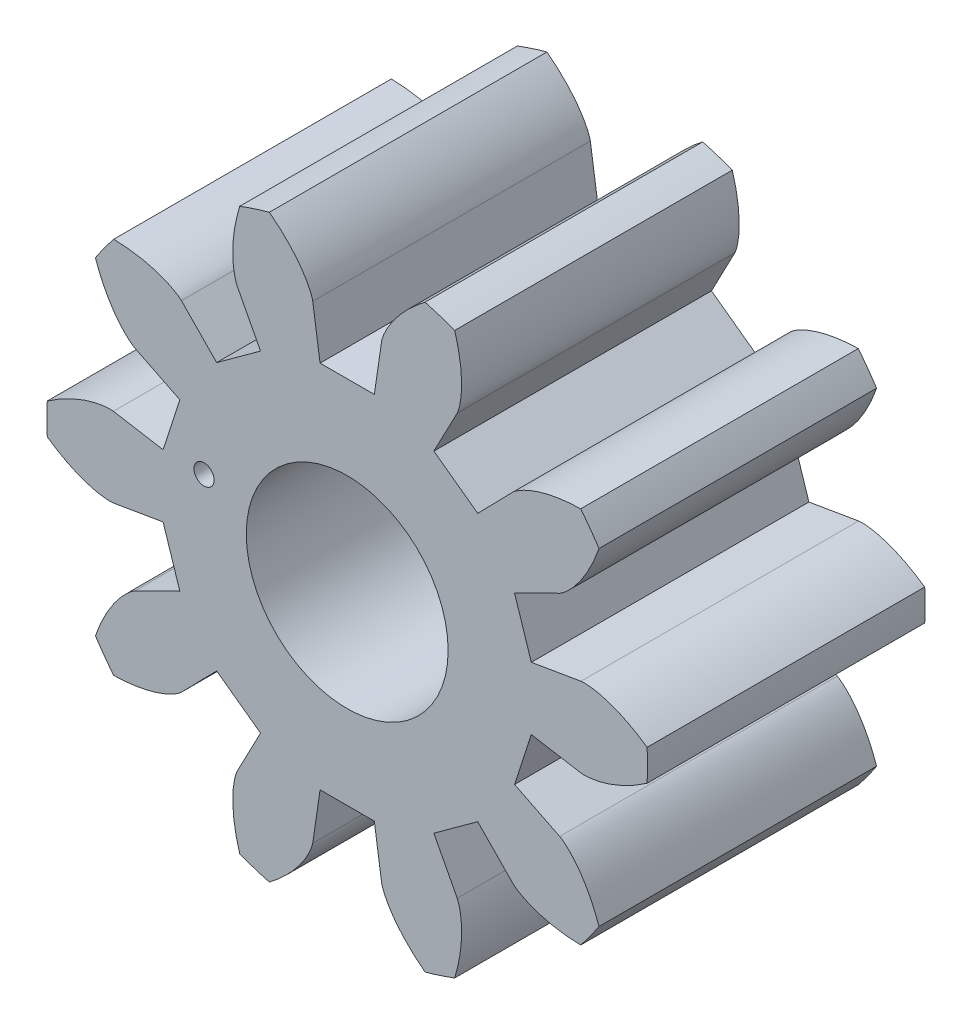
from build123d import *

# Parameters (mm, degrees)
SKETCH2_R               = 2.975
BOSS_EXTRUDE1_DEPTH     = 2.75
CUT_EXTRUDE2_DEPTH      = 6.0263058
CIRPATTERN1_COUNT       = 10
SKETCH3_R               = 1
CUT_EXTRUDE3_DEPTH      = 5.966777819
CUT_EXTRUDE6_DEPTH      = 5.966777819
CUT_EXTRUDE6_DEPTH_BACK = 5.966777819
SKETCH8_R               = 0.1


with BuildPart() as part:
    # Sketch2 → Boss-Extrude1 (new body)
    with BuildSketch(Plane.XY):
        Circle(SKETCH2_R)
    extrude(amount=BOSS_EXTRUDE1_DEPTH)

    # Sketch1 → Cut-Extrude2 (cut, through all)
    with BuildSketch(Plane.XY):
        with BuildLine():
            Line((2.105061689, 1.042882625), (1.657718296, 0.821261256))
            Line((1.657718296, 0.821261256), (1.823847528, 0.309968054))
            Line((1.823847528, 0.309968054), (2.316021708, 0.393614449))
            add(Edge.make_bspline(
                [(2.316021708, 0.393614449), (2.318929636, 0.394059611), (2.32446792, 0.394624012), (2.333537567, 0.395243685), (2.351499628, 0.395693398), (2.37186071, 0.395143687), (2.394878514, 0.393478775), (2.41960709, 0.390646462), (2.440730041, 0.387578139), (2.461769783, 0.383916799), (2.482692036, 0.379728548), (2.507978463, 0.3740182), (2.53821109, 0.366286196), (2.573383265, 0.35596726), (2.613051112, 0.342756753), (2.653190086, 0.327695817), (2.692432613, 0.311567142), (2.731740766, 0.293783952), (2.76952819, 0.275524287), (2.808369263, 0.255057903), (2.844018113, 0.235400613), (2.883451084, 0.211741965), (2.91513058, 0.192169028), (2.947397089, 0.170604832), (2.963032024, 0.159911869), (2.97099254, 0.154364272)],
                knots=[0, 0, 0, 0, 0, 0.015083688, 0.02853182, 0.046610139, 0.092110525, 0.119476176, 0.146842496, 0.174208854, 0.201574956, 0.228941013, 0.256307345, 0.307035032, 0.361767352, 0.416499661, 0.471231936, 0.525964282, 0.580696615, 0.635428982, 0.690161387, 0.744893688, 0.799626082, 0.854358408, 0.909090915, 0.909090915, 0.909090915, 0.909090915, 0.909090915], degree=4))
            ThreePointArc((2.97099254, 0.154364272), (2.829393136, 0.919325558), (2.494316497, 1.62142228))
            add(Edge.make_bspline(
                [(2.105061689, 1.042882625), (2.107675912, 1.044231719), (2.112488225, 1.047030431), (2.120189957, 1.05186011), (2.134985906, 1.062054119), (2.151135254, 1.074466788), (2.168778438, 1.089343256), (2.187119485, 1.106169737), (2.202404796, 1.121067821), (2.217274223, 1.136396758), (2.231738889, 1.152082916), (2.24883958, 1.171565673), (2.268753531, 1.195591288), (2.2911431, 1.224613169), (2.315470121, 1.258616869), (2.339090638, 1.294394519), (2.361358312, 1.33050907), (2.382706578, 1.368000725), (2.402544485, 1.404983995), (2.421937734, 1.444371858), (2.439223995, 1.481228807), (2.457219734, 1.523547175), (2.471344301, 1.558002753), (2.484773339, 1.594414333), (2.4911371, 1.612255106), (2.494316497, 1.62142228)],
                knots=[0, 0, 0, 0, 0, 0.015083688, 0.02853182, 0.046610139, 0.092110525, 0.119476176, 0.146842496, 0.174208854, 0.201574956, 0.228941013, 0.256307345, 0.307035032, 0.361767352, 0.416499661, 0.471231936, 0.525964282, 0.580696615, 0.635428982, 0.690161387, 0.744893688, 0.799626082, 0.854358408, 0.909090915, 0.909090915, 0.909090915, 0.909090915, 0.909090915], degree=4))
        make_face()
    cut_extrude2 = extrude(amount=CUT_EXTRUDE2_DEPTH, mode=Mode.SUBTRACT)

    # CirPattern1: Cut-Extrude2 ×10 about axis
    cirpattern1_axis = Axis((0, 0, 4.582847529), (0, 0, -1))
    for i in range(1, CIRPATTERN1_COUNT):
        add(cut_extrude2.rotate(cirpattern1_axis, i * 360 / CIRPATTERN1_COUNT), mode=Mode.SUBTRACT)

    # Sketch3 → Cut-Extrude3 (cut, through all)
    with BuildSketch(Plane.XY):
        Circle(SKETCH3_R)
    extrude(amount=CUT_EXTRUDE3_DEPTH, mode=Mode.SUBTRACT)

    # Sketch8 → Cut-Extrude6 (cut, two sides: drawn at the far end of the back side and taken through both)
    with BuildSketch(Plane.XY.offset(-CUT_EXTRUDE6_DEPTH_BACK)):
        with Locations((-1.418314021, 0.301471952)):
            Circle(SKETCH8_R)
    extrude(amount=CUT_EXTRUDE6_DEPTH + CUT_EXTRUDE6_DEPTH_BACK, mode=Mode.SUBTRACT)


solid = part.part
